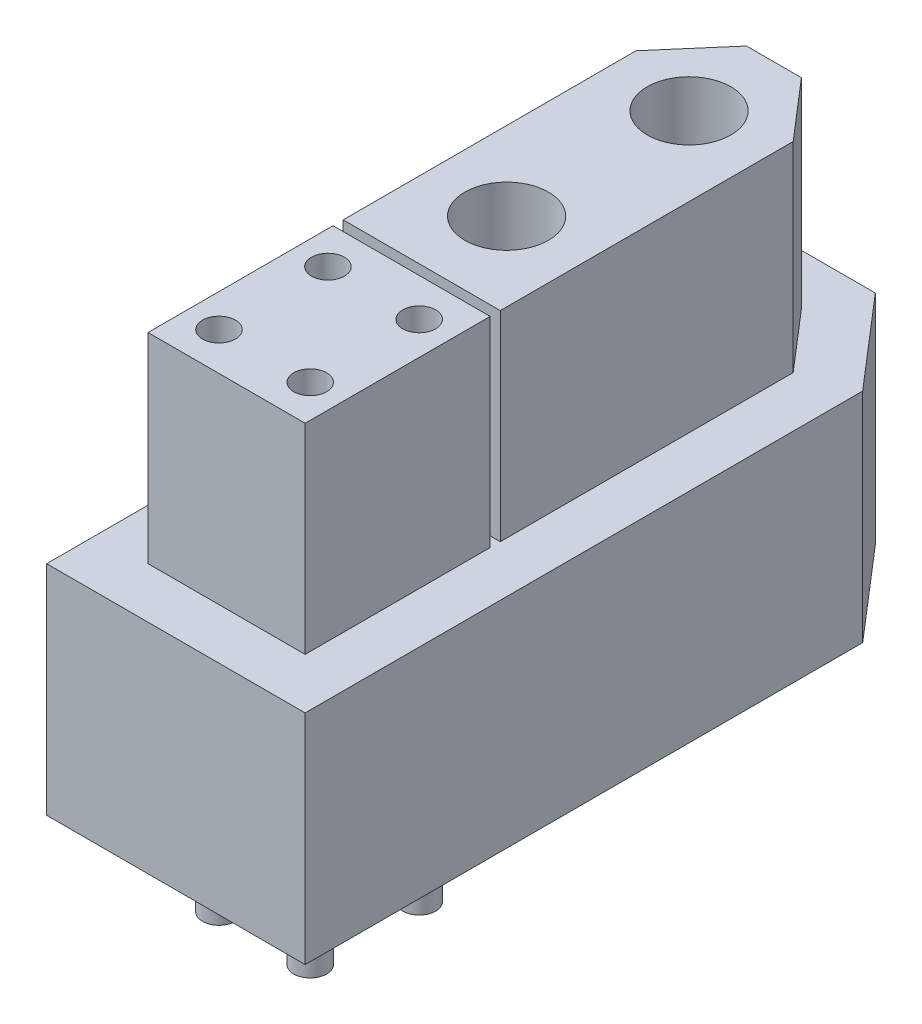
from build123d import *

# Parameters (mm, degrees)
EXTRUDE_1_DEPTH = 8.6
SKETCH_2_R      = 1.65
SKETCH_2_W      = 6.2
SKETCH_2_H      = 7.3
SKETCH_2_R_2    = 0.65
EXTRUDE_2_DEPTH = 7.9
SKETCH_3_R      = 1.65
SKETCH_3_R_2    = 0.65
EXTRUDE_3_DEPTH = 12


with BuildPart() as part:
    # 草图1 → 凸台-拉伸1 (new body)
    with BuildSketch(Plane(origin=(0, 0, 0), x_dir=(1, 0, 0), z_dir=(0, 1, 0))):
        Polygon((0, 0), (0, 22), (3.1, 25.6), (7.1, 25.6), (10.2, 22), (10.2, 0), align=None)
    extrude(amount=EXTRUDE_1_DEPTH)

    # 草图2 → 凸台-拉伸2 (add)
    with BuildSketch(Plane(origin=(0, 8.6, 0), x_dir=(1, 0, 0), z_dir=(0, 1, 0))):
        Polygon((2, 9.7), (8.2, 9.7), (8.2, 21.257555221), (6.182894773, 23.6), (4.017105227, 23.6), (2, 21.257555221), align=None)
        with Locations((5.1, 20.25)):
            Circle(SKETCH_2_R, mode=Mode.SUBTRACT)
        with Locations((5.1, 13.05)):
            Circle(SKETCH_2_R, mode=Mode.SUBTRACT)
        with Locations((5.1, 5.65)):
            Rectangle(SKETCH_2_W, SKETCH_2_H)
        with Locations((3.3, 7.8)):
            Circle(SKETCH_2_R_2, mode=Mode.SUBTRACT)
        with Locations((6.9, 7.8)):
            Circle(SKETCH_2_R_2, mode=Mode.SUBTRACT)
        with Locations((6.9, 3.5)):
            Circle(SKETCH_2_R_2, mode=Mode.SUBTRACT)
        with Locations((3.3, 3.5)):
            Circle(SKETCH_2_R_2, mode=Mode.SUBTRACT)
    extrude(amount=EXTRUDE_2_DEPTH)

    # 草图3 → 凸台-拉伸3 (add)
    with BuildSketch(Plane(origin=(0, 8.6, 0), x_dir=(1, 0, 0), z_dir=(0, 1, 0))):
        with Locations((5.1, 20.25)):
            Circle(SKETCH_3_R)
        with Locations((5.1, 13.05)):
            Circle(SKETCH_3_R)
        with Locations((3.3, 7.8)):
            Circle(SKETCH_3_R_2)
        with Locations((6.9, 7.8)):
            Circle(SKETCH_3_R_2)
        with Locations((6.9, 3.5)):
            Circle(SKETCH_3_R_2)
        with Locations((3.3, 3.5)):
            Circle(SKETCH_3_R_2)
    extrude(amount=-EXTRUDE_3_DEPTH)


solid = part.part
